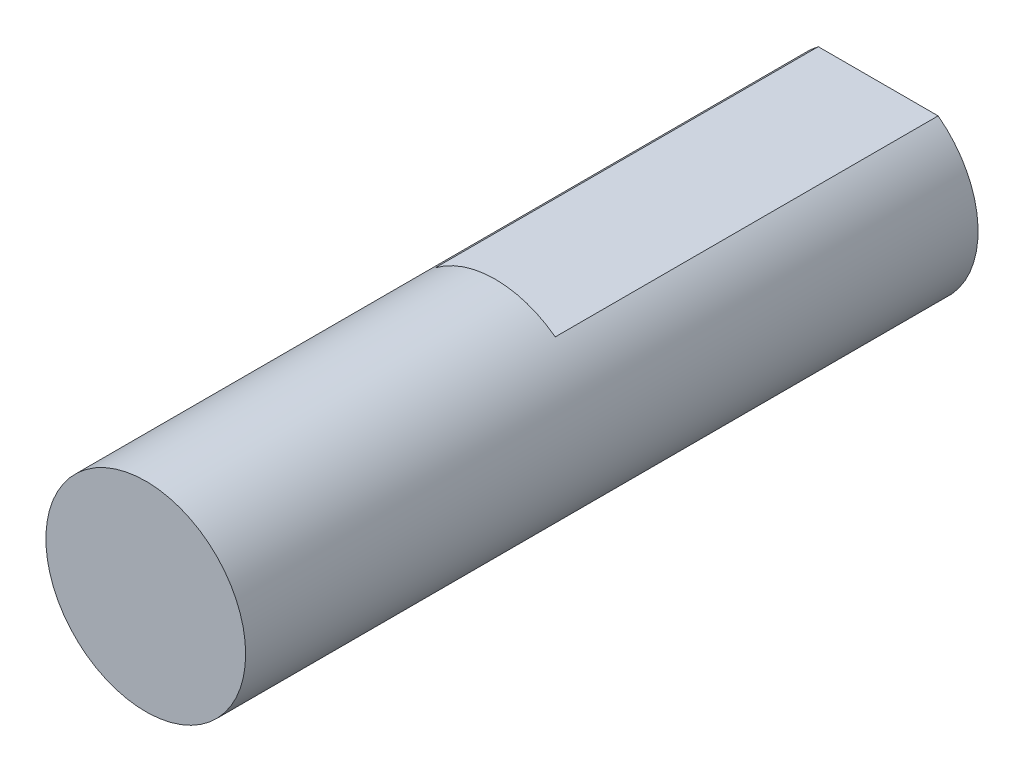
from build123d import *

# Parameters (mm, degrees)
SKETCH1_R           = 3
BOSS_EXTRUDE1_DEPTH = 22
CUT_EXTRUDE1_DEPTH  = 11.5


with BuildPart() as part:
    # Sketch1 → Boss-Extrude1 (new body)
    with BuildSketch(Plane.XY):
        Circle(SKETCH1_R)
    extrude(amount=BOSS_EXTRUDE1_DEPTH)

    # Sketch1_3 → Cut-Extrude1 (cut)
    with BuildSketch(Plane.XY):
        Polygon((-26.249913495, 2.4), (-1.8, 2.4), (1.8, 2.4), (26.249913495, 2.4), (26.249913495, 51.299826989), (-26.249913495, 51.299826989), align=None)
    extrude(amount=CUT_EXTRUDE1_DEPTH, mode=Mode.SUBTRACT)


solid = part.part
